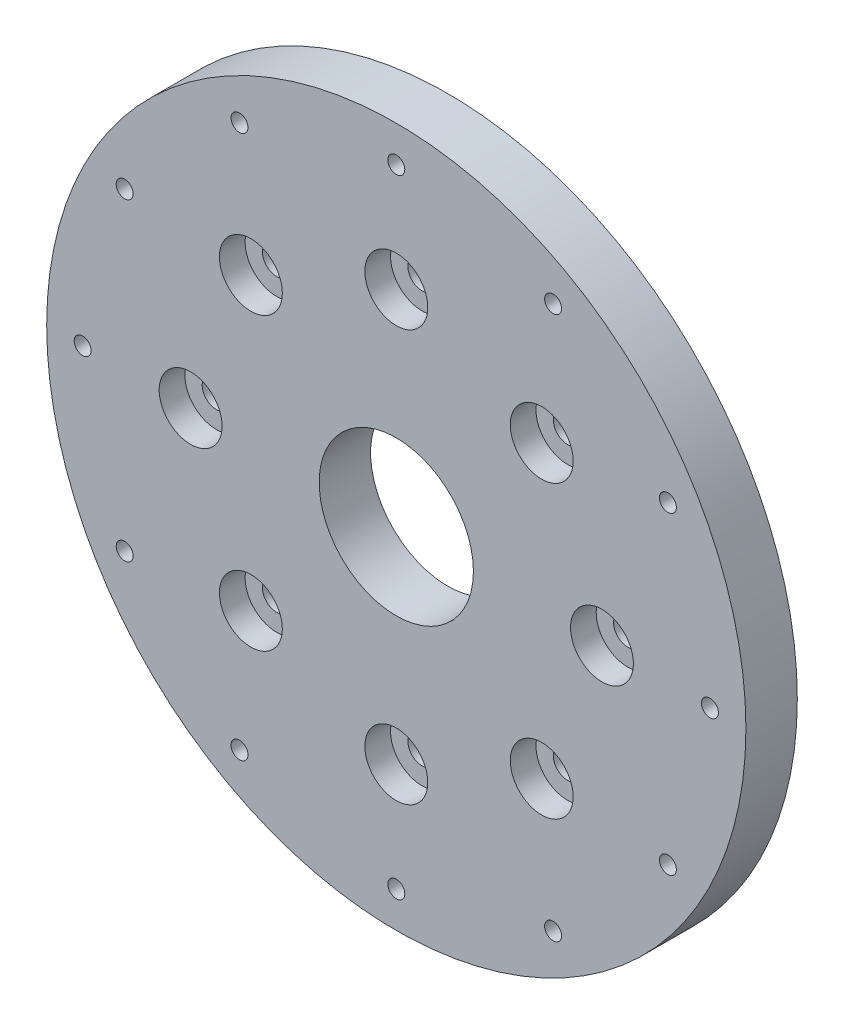
from build123d import *

# Parameters (mm, degrees)
SKETCH1_R                               = 75
BOSS_EXTRUDE1_DEPTH                     = 10
SKETCH3_R                               = 15
CUT_EXTRUDE2_DEPTH                      = 10
SKETCH8_R                               = 55
SKETCH8_R_2                             = 53
CUT_EXTRUDE7_DEPTH                      = 1.3208
CBORE_FOR_M5_HEX_HEAD_BOLT1_D           = 5.5
CBORE_FOR_M5_HEX_HEAD_BOLT1_CBORE_D     = 12.238
CBORE_FOR_M5_HEX_HEAD_BOLT1_CBORE_DEPTH = 3.5
SKETCH11_R                              = 75
SKETCH11_R_2                            = 68
CUT_EXTRUDE8_DEPTH                      = 10
SKETCH12_R                              = 6.119
CUT_EXTRUDE9_DEPTH                      = 5
CIRPATTERN2_COUNT                       = 8
M4_TAPPED_HOLE1_D                       = 3.3
CIRPATTERN3_COUNT                       = 12


with BuildPart() as part:
    # Sketch1 → Boss-Extrude1 (new body)
    with BuildSketch(Plane.XY):
        Circle(SKETCH1_R)
    extrude(amount=BOSS_EXTRUDE1_DEPTH)

    # Sketch3 → Cut-Extrude2 (cut)
    with BuildSketch(Plane.XY.offset(10)):
        Circle(SKETCH3_R)
    extrude(amount=-CUT_EXTRUDE2_DEPTH, mode=Mode.SUBTRACT)

    # Sketch8 → Cut-Extrude7 (cut)
    with BuildSketch(Plane.XY):
        Circle(SKETCH8_R)
        Circle(SKETCH8_R_2, mode=Mode.SUBTRACT)
    extrude(amount=CUT_EXTRUDE7_DEPTH, mode=Mode.SUBTRACT)

    # CBORE for M5 Hex Head Bolt1 (through all)
    with Locations(Plane.XY.offset(10)):
        with Locations((28.284271247, 28.284271247)):
            cbore_for_m5_hex_head_bolt1 = CounterBoreHole(CBORE_FOR_M5_HEX_HEAD_BOLT1_D / 2, CBORE_FOR_M5_HEX_HEAD_BOLT1_CBORE_D / 2, CBORE_FOR_M5_HEX_HEAD_BOLT1_CBORE_DEPTH)

    # Sketch11 → Cut-Extrude8 (cut)
    with BuildSketch(Plane.XY.offset(10)):
        Circle(SKETCH11_R)
        Circle(SKETCH11_R_2, mode=Mode.SUBTRACT)
    extrude(amount=-CUT_EXTRUDE8_DEPTH, mode=Mode.SUBTRACT)

    # Sketch12 → Cut-Extrude9 (cut)
    with BuildSketch(Plane.XY.offset(10)):
        with Locations((28.284271247, 28.284271247)):
            Circle(SKETCH12_R)
    cut_extrude9 = extrude(amount=-CUT_EXTRUDE9_DEPTH, mode=Mode.SUBTRACT)

    # CirPattern2: CBORE for M5 Hex Head Bolt1, Cut-Extrude9 ×8 about axis
    cirpattern2_axis = Axis((0, 0, 0), (0, 0, 1))
    for i in range(1, CIRPATTERN2_COUNT):
        add(cbore_for_m5_hex_head_bolt1.rotate(cirpattern2_axis, i * 360 / CIRPATTERN2_COUNT), mode=Mode.SUBTRACT)
        add(cut_extrude9.rotate(cirpattern2_axis, i * 360 / CIRPATTERN2_COUNT), mode=Mode.SUBTRACT)

    # M4 Tapped Hole1 (through all)
    with Locations(Plane.XY.offset(10)):
        with Locations((0, 61)):
            m4_tapped_hole1 = Hole(M4_TAPPED_HOLE1_D / 2)

    # CirPattern3: M4 Tapped Hole1 ×12 about axis
    cirpattern3_axis = Axis((0, 0, 0), (0, 0, 1))
    for i in range(1, CIRPATTERN3_COUNT):
        add(m4_tapped_hole1.rotate(cirpattern3_axis, i * 360 / CIRPATTERN3_COUNT), mode=Mode.SUBTRACT)


solid = part.part
